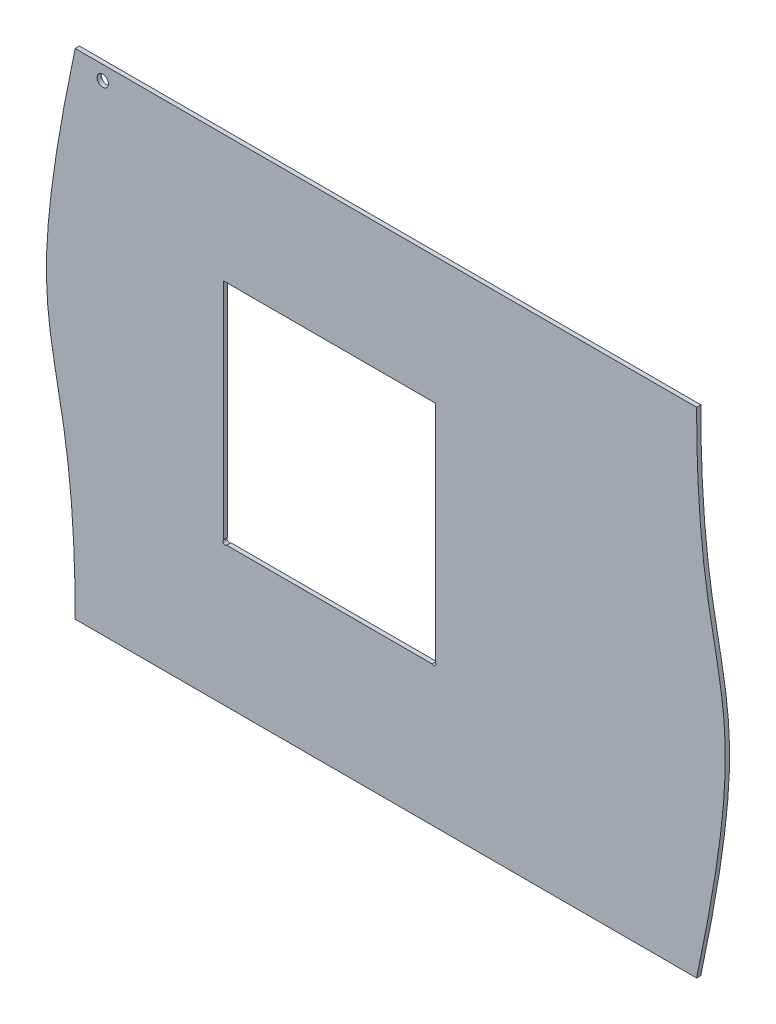
from build123d import *

# Parameters (mm, degrees)
ESQUISSE1_R        = 4
BOSS_EXTRU_1_DEPTH = 3


with BuildPart() as part:
    # Esquisse1 → Boss.-Extru.1 (new body)
    with BuildSketch(Plane.XY):
        with BuildLine():
            Line((-10, 8), (430, 8))
            add(Edge.make_bspline(
                [(430, 8), (475.762038199, 224.87493493), (430, 170.54141189), (430, 358)],
                knots=[0, 0, 0, 0, 1, 1, 1, 1], degree=3))
            Line((430, 358), (-10, 358))
            add(Edge.make_bspline(
                [(-10, 358), (-55.762038199, 141.12506507), (-10, 195.458588109), (-10, 8)],
                knots=[0, 0, 0, 0, 1, 1, 1, 1], degree=3))
        make_face()
        with Locations((9.5, 348)):
            Circle(ESQUISSE1_R, mode=Mode.SUBTRACT)
        with BuildLine():
            Line((95, 268), (95, 109.2627417))
            ThreePointArc((95, 109.2627417), (95, 107), (97.2627417, 107))
            Line((97.2627417, 107), (242.7372583, 107))
            ThreePointArc((242.7372583, 107), (245, 107), (245, 109.2627417))
            Line((245, 109.2627417), (245, 268))
            Line((245, 268), (95, 268))
        make_face(mode=Mode.SUBTRACT)
    extrude(amount=BOSS_EXTRU_1_DEPTH)


solid = part.part
